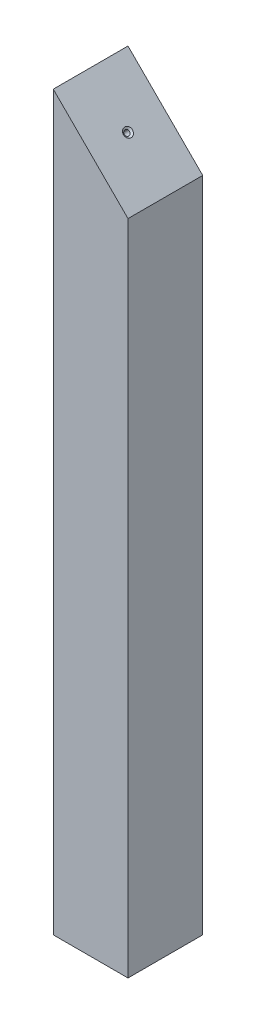
from build123d import *

# Parameters (mm, degrees)
SKETCH1_W                                         = 25.4
SKETCH1_H                                         = 25.4
BOSS_EXTRUDE1_DEPTH                               = 124.485
F_0_80_TAPPED_HOLE1_D                             = 1.19126
F_0_80_TAPPED_HOLE1_DEPTH                         = 20
F_0_80_TAPPED_HOLE1_CSINK_D                       = 3.0226
F_0_80_TAPPED_HOLE1_CSINK_ANGLE                   = 100
F_0_80_TAPPED_HOLE1_TIP                           = 0.357890611
CUT_EXTRUDE1_DEPTH                                = 13.7
CUT_EXTRUDE1_DEPTH_BACK                           = 13.7
CSK_FOR_0_FLAT_HEAD_MACHINE_SCREW_100_D           = 1.778
CSK_FOR_0_FLAT_HEAD_MACHINE_SCREW_100_DEPTH       = 10
CSK_FOR_0_FLAT_HEAD_MACHINE_SCREW_100_CSINK_D     = 3.0226
CSK_FOR_0_FLAT_HEAD_MACHINE_SCREW_100_CSINK_ANGLE = 100
CSK_FOR_0_FLAT_HEAD_MACHINE_SCREW_100_TIP         = 0.53416509


with BuildPart() as part:
    # Sketch1 → Boss-Extrude1 (new body, symmetric)
    with BuildSketch(Plane(origin=(0, 0, 0), x_dir=(1, 0, 0), z_dir=(0, 1, 0))):
        Rectangle(SKETCH1_W, SKETCH1_H)
    extrude(amount=BOSS_EXTRUDE1_DEPTH, both=True)

    # #0-80 Tapped Hole1
    with Locations(Plane(origin=(0, -124.485, 0), x_dir=(-1, 0, 0), z_dir=(0, -1, 0))):
        with Locations((0, 0)):
            CounterSinkHole(F_0_80_TAPPED_HOLE1_D / 2, F_0_80_TAPPED_HOLE1_CSINK_D / 2, depth=F_0_80_TAPPED_HOLE1_DEPTH, counter_sink_angle=F_0_80_TAPPED_HOLE1_CSINK_ANGLE)
            with Locations((0, 0, -(F_0_80_TAPPED_HOLE1_DEPTH + F_0_80_TAPPED_HOLE1_TIP / 2))):  # 118° drill point
                Cone(0, F_0_80_TAPPED_HOLE1_D / 2, F_0_80_TAPPED_HOLE1_TIP, mode=Mode.SUBTRACT)

    # Sketch4 → Cut-Extrude1 (cut, two sides)
    with BuildSketch(Plane.XY) as cut_extrude1_sk:
        Polygon((12.7, 124.485), (-12.7, 124.485), (12.7, 99.085), align=None)
    extrude(amount=CUT_EXTRUDE1_DEPTH, mode=Mode.SUBTRACT)
    extrude(cut_extrude1_sk.sketch, amount=-CUT_EXTRUDE1_DEPTH_BACK, mode=Mode.SUBTRACT)

    # CSK for #0 Flat Head Machine Screw (100)1
    with Locations(Plane(origin=(55.8925, 55.8925, 0), x_dir=(0.707106781, -0.707106781, 0), z_dir=(0.707106781, 0.707106781, 0))):
        with Locations((-79.043931535, 0)):
            CounterSinkHole(CSK_FOR_0_FLAT_HEAD_MACHINE_SCREW_100_D / 2, CSK_FOR_0_FLAT_HEAD_MACHINE_SCREW_100_CSINK_D / 2, depth=CSK_FOR_0_FLAT_HEAD_MACHINE_SCREW_100_DEPTH, counter_sink_angle=CSK_FOR_0_FLAT_HEAD_MACHINE_SCREW_100_CSINK_ANGLE)
            with Locations((0, 0, -(CSK_FOR_0_FLAT_HEAD_MACHINE_SCREW_100_DEPTH + CSK_FOR_0_FLAT_HEAD_MACHINE_SCREW_100_TIP / 2))):  # 118° drill point
                Cone(0, CSK_FOR_0_FLAT_HEAD_MACHINE_SCREW_100_D / 2, CSK_FOR_0_FLAT_HEAD_MACHINE_SCREW_100_TIP, mode=Mode.SUBTRACT)


solid = part.part
